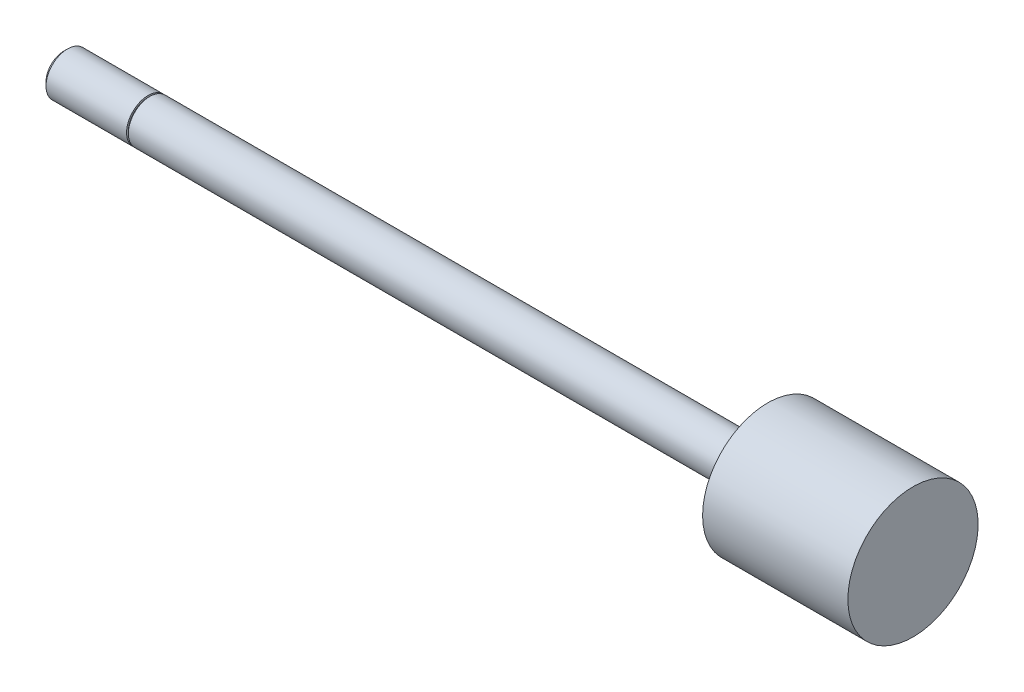
from build123d import *

# Parameters (mm, degrees)
SKETCH3_W = 0.254
SKETCH3_H = 0.508


with BuildPart() as part:
    # Sketch1 → Revolve1 (revolve)
    with BuildSketch(Plane.XY):
        Polygon((0, 0), (0, 3.175), (91.2876, 3.175), (91.2876, 9.62025), (112.7506, 9.62025), (112.7506, 0), align=None)
    revolve(axis=Axis((112.7506, 0, 0), (-1, 0, 0)))

    # Sketch2 → Revolve2 (revolve)
    with BuildSketch(Plane.XY):
        Polygon((-12.7, 0), (-12.7, 2.63398), (-12.15898, 3.175), (0, 3.175), (0, 0), align=None)
    revolve(axis=Axis((0, 0, 0), (-1, 0, 0)))

    # Sketch3 → Cut-Revolve1 (revolve, cut)
    with BuildSketch(Plane.XY):
        with Locations((-0.127, 3.175)):
            Rectangle(SKETCH3_W, SKETCH3_H)
    revolve(axis=Axis((0, 0, 0), (-1, 0, 0)), mode=Mode.SUBTRACT)


solid = part.part
